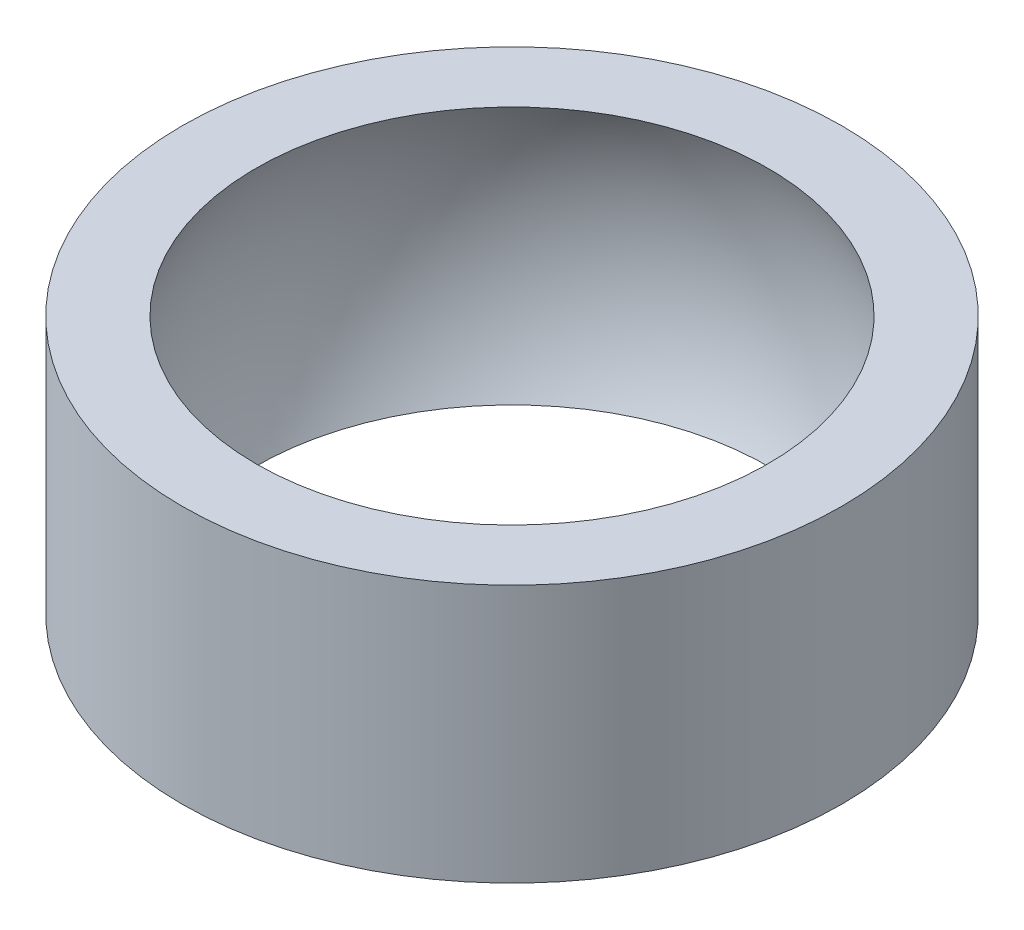
from build123d import *

# Parameters (mm, degrees)
SKETCH1_R           = 11.5
SKETCH1_R_2         = 8.5
BOSS_EXTRUDE1_DEPTH = 9


with BuildPart() as part:
    # Sketch1 → Boss-Extrude1 (new body)
    with BuildSketch(Plane(origin=(0, 0, 0), x_dir=(1, 0, 0), z_dir=(0, 1, 0))):
        Circle(SKETCH1_R)
        Circle(SKETCH1_R_2, mode=Mode.SUBTRACT)
    extrude(amount=BOSS_EXTRUDE1_DEPTH)

    # Sketch2 → Cut-Revolve2 (revolve, cut)
    with BuildSketch(Plane.XY):
        with BuildLine():
            Line((0, -5.5), (0, 14.5))
            ThreePointArc((0, 14.5), (10, 4.5), (0, -5.5))
        make_face()
    revolve(axis=Axis((0, -5.5, 0), (0, 1, 0)), mode=Mode.SUBTRACT)


solid = part.part
